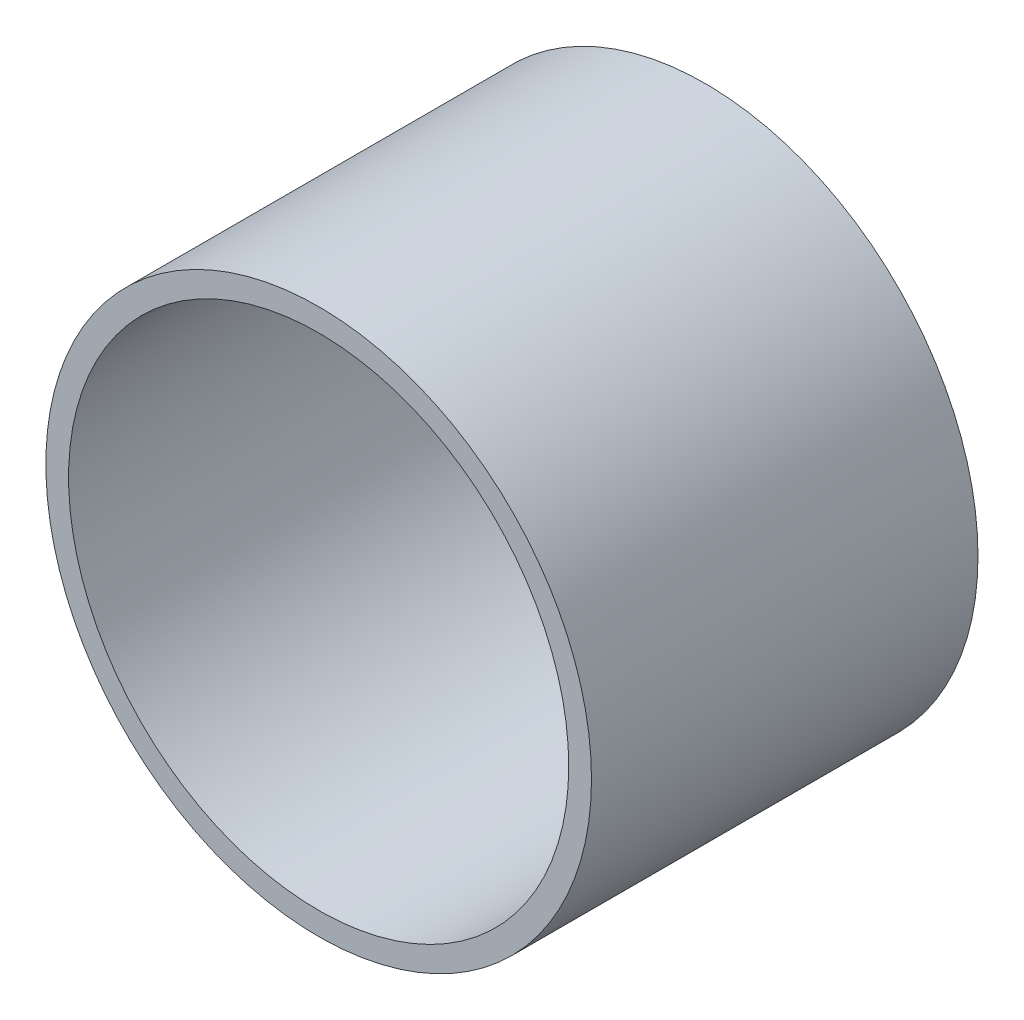
from build123d import *

# Parameters (mm, degrees)
SKETCH1_R           = 76.2
SKETCH1_R_2         = 69.85
BOSS_EXTRUDE1_DEPTH = 107.95
SKETCH3_R           = 76.2
BOSS_EXTRUDE2_DEPTH = 6.35
SKETCH5_R           = 2.1828125
CUT_EXTRUDE2_DEPTH  = 7.35
SKETCH11_R          = 2.1828125
CUT_EXTRUDE11_DEPTH = 7.35
SKETCH4_3_W         = 38.1
SKETCH4_3_H         = 38.1
BOSS_EXTRUDE3_DEPTH = 19.05


with BuildPart() as part:
    # Sketch1 → Boss-Extrude1 (new body)
    with BuildSketch(Plane.XY):
        Circle(SKETCH1_R)
        Circle(SKETCH1_R_2, mode=Mode.SUBTRACT)
    extrude(amount=BOSS_EXTRUDE1_DEPTH)

    # Sketch3 → Boss-Extrude2 (add)
    with BuildSketch(Plane.XY):
        Circle(SKETCH3_R)
    extrude(amount=BOSS_EXTRUDE2_DEPTH)

    # Sketch5 → Cut-Extrude2 (cut, through all)
    with BuildSketch(Plane.XY.offset(6.35)):
        with Locations((0, 37.81298)):
            Circle(SKETCH5_R)
        with Locations((37.81298, 0)):
            Circle(SKETCH5_R)
        with Locations((-37.81298, 0)):
            Circle(SKETCH5_R)
        with Locations((0, -37.81298)):
            Circle(SKETCH5_R)
    extrude(amount=-CUT_EXTRUDE2_DEPTH, mode=Mode.SUBTRACT)

    # Sketch11 → Cut-Extrude11 (cut, through all)
    with BuildSketch(Plane.XY.offset(6.35)):
        with Locations((-35.921024484, 35.921024484)):
            Circle(SKETCH11_R)
        with Locations((-35.921024484, -35.921024484)):
            Circle(SKETCH11_R)
        with Locations((35.921024484, -35.921024484)):
            Circle(SKETCH11_R)
        with Locations((35.921024484, 35.921024484)):
            Circle(SKETCH11_R)
    extrude(amount=-CUT_EXTRUDE11_DEPTH, mode=Mode.SUBTRACT)

    # Sketch4_3 → Boss-Extrude3 (add)
    with BuildSketch(Plane.XY.offset(6.35)):
        Rectangle(SKETCH4_3_W, SKETCH4_3_H)
    extrude(amount=BOSS_EXTRUDE3_DEPTH)


solid = part.part
